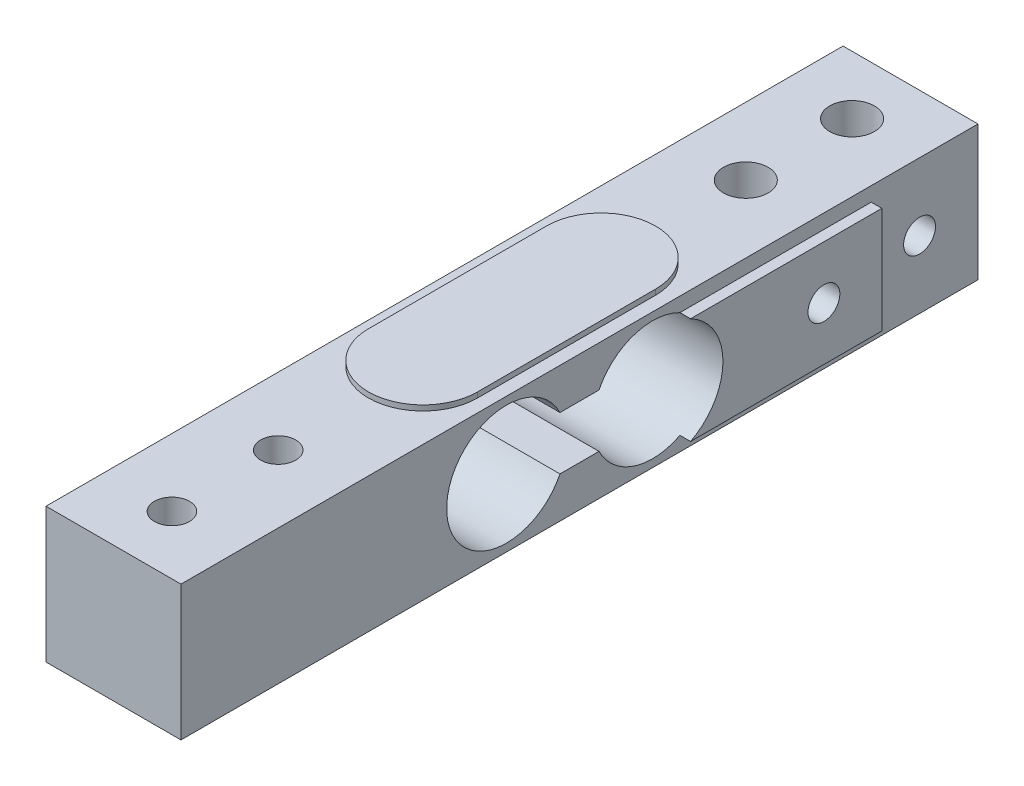
from build123d import *

# Parameters (mm, degrees)
SKETCH1_W               = 75
SKETCH1_H               = 12.7
BOSS_EXTRUDE1_DEPTH     = 6.35
CUT_EXTRUDE1_DEPTH      = 39.560277489
CUT_EXTRUDE1_DEPTH_BACK = 39.560277489
SKETCH2_R               = 5.625
CUT_EXTRUDE2_DEPTH      = 39.560277489
CUT_EXTRUDE2_DEPTH_BACK = 39.560277489
SKETCH3_W               = 23.827822186
SKETCH3_H               = 5
M4X0_7_TAPPED_HOLE1_D   = 3.3
GOO_DEPTH               = 0.5
BOSS_EXTRUDE5_DEPTH     = 1
F_3_0MM_DOWEL_HOLE1_D   = 3
M5X0_8_TAPPED_HOLE1_D   = 4.2


with BuildPart() as part:
    # Sketch1 → Boss-Extrude1 (new, symmetric)
    with BuildSketch(Plane(origin=(0, 0, 0), x_dir=(0, 0, -1), z_dir=(1, 0, 0))):
        Rectangle(SKETCH1_W, SKETCH1_H)
    extrude(amount=BOSS_EXTRUDE1_DEPTH, both=True)

    # Sketch2 → Cut-Extrude1 (cut, two sides: drawn at the far end of the back side and taken through both)
    with BuildSketch(Plane(origin=(0, 0, 0), x_dir=(0, 0, -1), z_dir=(1, 0, 0)).offset(-CUT_EXTRUDE1_DEPTH_BACK)):
        with Locations((-6.875, 0)):
            Circle(SKETCH2_R)
        with Locations((6.875, 0)):
            Circle(SKETCH2_R)
    extrude(amount=CUT_EXTRUDE1_DEPTH + CUT_EXTRUDE1_DEPTH_BACK, mode=Mode.SUBTRACT)

    # Sketch3 → Cut-Extrude2 (cut, two sides: drawn at the far end of the back side and taken through both)
    with BuildSketch(Plane(origin=(0, 0, 0), x_dir=(0, 0, -1), z_dir=(1, 0, 0)).offset(-CUT_EXTRUDE2_DEPTH_BACK)):
        Rectangle(SKETCH3_W, SKETCH3_H)
    extrude(amount=CUT_EXTRUDE2_DEPTH + CUT_EXTRUDE2_DEPTH_BACK, mode=Mode.SUBTRACT)

    # M4x0.7 Tapped Hole1 (through all)
    with Locations(Plane(origin=(0, 6.35, 0), x_dir=(1, 0, 0), z_dir=(0, 1, 0))):
        with Locations((0, 32), (0, 22), (0, -22), (0, -32)):
            Hole(M4X0_7_TAPPED_HOLE1_D / 2)

    # Sketch8 → Goo (add, symmetric)
    with BuildSketch(Plane(origin=(0, 6.35, 0), x_dir=(1, 0, 0), z_dir=(0, 1, 0))):
        with BuildLine():
            Line((-5.13731221, -8.377770681), (-5.13731221, 8.377770681))
            ThreePointArc((-5.13731221, 8.377770681), (0, 13.515082891), (5.13731221, 8.377770681))
            Line((5.13731221, 8.377770681), (5.13731221, -8.377770681))
            ThreePointArc((5.13731221, -8.377770681), (0, -13.515082891), (-5.13731221, -8.377770681))
        make_face()
    goo = extrude(amount=GOO_DEPTH, both=True)

    # Mirror1: Goo across plane
    add(goo.mirror(Plane.ZX))

    # Sketch9 → Boss-Extrude5 (add, symmetric)
    with BuildSketch(Plane(origin=(6.35, 0, 0), x_dir=(0, 0, -1), z_dir=(1, 0, 0))):
        with BuildLine():
            Line((9.451941016, -5), (27.451941016, -5))
            Line((27.451941016, -5), (27.451941016, 5))
            Line((27.451941016, 5), (9.451941016, 5))
            ThreePointArc((9.451941016, 5), (12.5, 0), (9.451941016, -5))
        make_face()
    extrude(amount=BOSS_EXTRUDE5_DEPTH, both=True)

    # Ø3.0mm Dowel Hole1 (through all)
    with Locations(Plane.ZY.offset(6.35)):
        with Locations((-22, 0), (-32, 0)):
            Hole(F_3_0MM_DOWEL_HOLE1_D / 2)

    # M5x0.8 Tapped Hole1 (through all)
    with Locations(Plane(origin=(0, 6.35, 0), x_dir=(1, 0, 0), z_dir=(0, 1, 0))):
        with Locations((0, 32), (0, 22)):
            Hole(M5X0_8_TAPPED_HOLE1_D / 2)


solid = part.part
